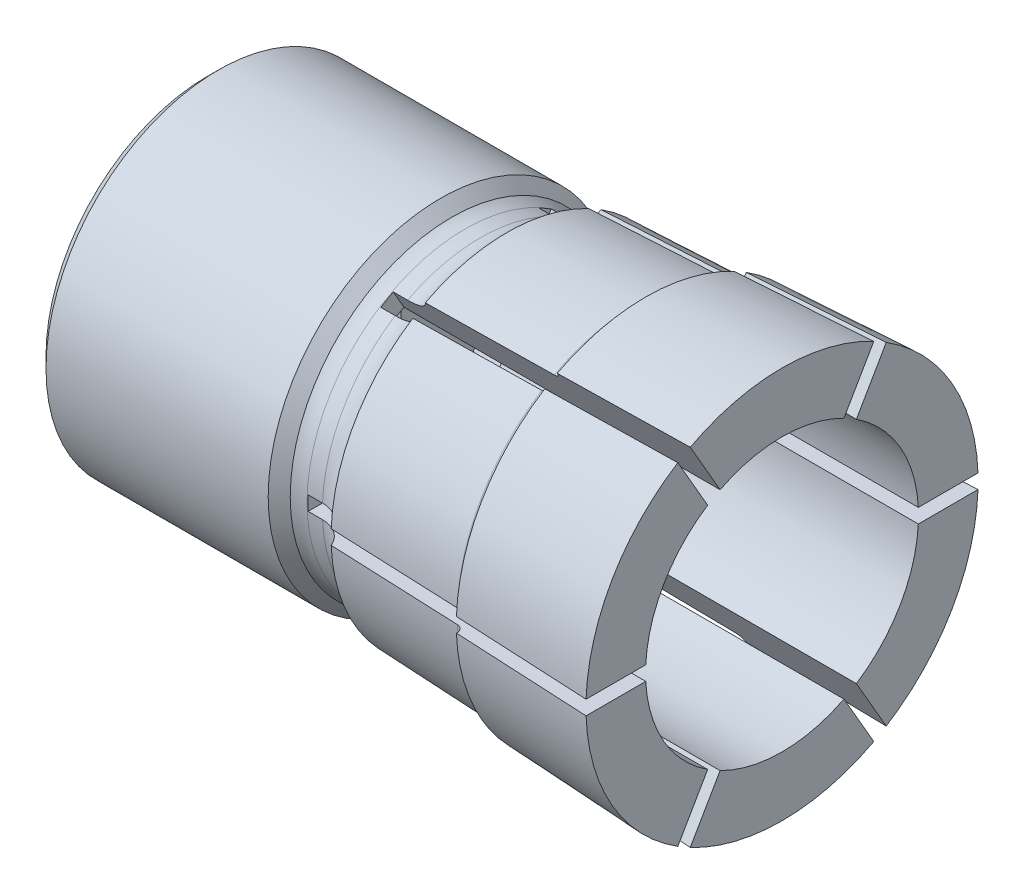
from build123d import *

# Parameters (mm, degrees)
CUT_EXTRUDE1_DEPTH = 6
CUT_EXTRUDE2_DEPTH = 40


with BuildPart() as part:
    # Sketch1 → Revolve1 (revolve)
    with BuildSketch(Plane.XY):
        with BuildLine():
            Line((8.054036255, 0), (0, 4.65))
            Line((0, 4.65), (0, 11.233))
            Line((0, 11.233), (0.767, 12))
            Line((0.767, 12), (16.233, 12))
            Line((16.233, 12), (16.999844549, 11.233155451))
            ThreePointArc((16.999844549, 11.233155451), (17.454138269, 11.059163956), (17.937, 11))
            Line((17.937, 11), (19, 11))
            ThreePointArc((19, 11), (20.115234375, 11.339803539), (20.851508163, 12.243747712))
            Line((20.851508163, 12.243747712), (30.021033995, 12.62983301))
            ThreePointArc((30.021033995, 12.62983301), (30.360913423, 12.783353536), (30.5, 13.129390385))
            Line((30.5, 13.129390385), (30.5, 13.175))
            Line((30.5, 13.175), (40, 13.65))
            Line((40, 13.65), (40, 0))
            Line((40, 0), (8.054036255, 0))
        make_face()
    revolve(axis=Axis((40, 0, 0), (-1, 0, 0)))

    # Sketch2 → Cut-Extrude1 (cut)
    with BuildSketch(Plane(origin=(0, 0, 0), x_dir=(0, 0, -1), z_dir=(1, 0, 0))):
        Polygon((-4, -2.309401077), (0, -4.618802154), (4, -2.309401077), (4, 2.309401077), (0, 4.618802154), (-4, 2.309401077), align=None)
    extrude(amount=CUT_EXTRUDE1_DEPTH, mode=Mode.SUBTRACT)

    # Sketch3 → Cut-Revolve1 (revolve, cut)
    with BuildSketch(Plane(origin=(0, 0, 0), x_dir=(1, 0, 0), z_dir=(0, 1, 0))):
        Polygon((6, 0), (6, 4.75), (8, 4.75), (8, 3.5), (10, 3.5), (10, 9.7), (12, 9.7), (12, 9.5), (42, 9.5), (42, 0), align=None)
    revolve(axis=Axis((42, 0, 0), (-1, 0, 0)), mode=Mode.SUBTRACT)

    # Sketch4 → Cut-Extrude2 (cut)
    with BuildSketch(Plane(origin=(18, 0, 0), x_dir=(0, 0, -1), z_dir=(1, 0, 0))):
        Polygon((-18.65, 0.5), (-18.65, -0.5), (-0.866025404, -0.5), (-9.758012702, -15.901373781), (-8.891987298, -16.401373781), (0, -1), (8.891987298, -16.401373781), (9.758012702, -15.901373781), (0.866025404, -0.5), (18.65, -0.5), (18.65, 0.5), (0.866025404, 0.5), (9.758012702, 15.901373781), (8.891987298, 16.401373781), (0, 1), (-8.891987298, 16.401373781), (-9.758012702, 15.901373781), (-0.866025404, 0.5), align=None)
    extrude(amount=CUT_EXTRUDE2_DEPTH, mode=Mode.SUBTRACT)


solid = part.part
